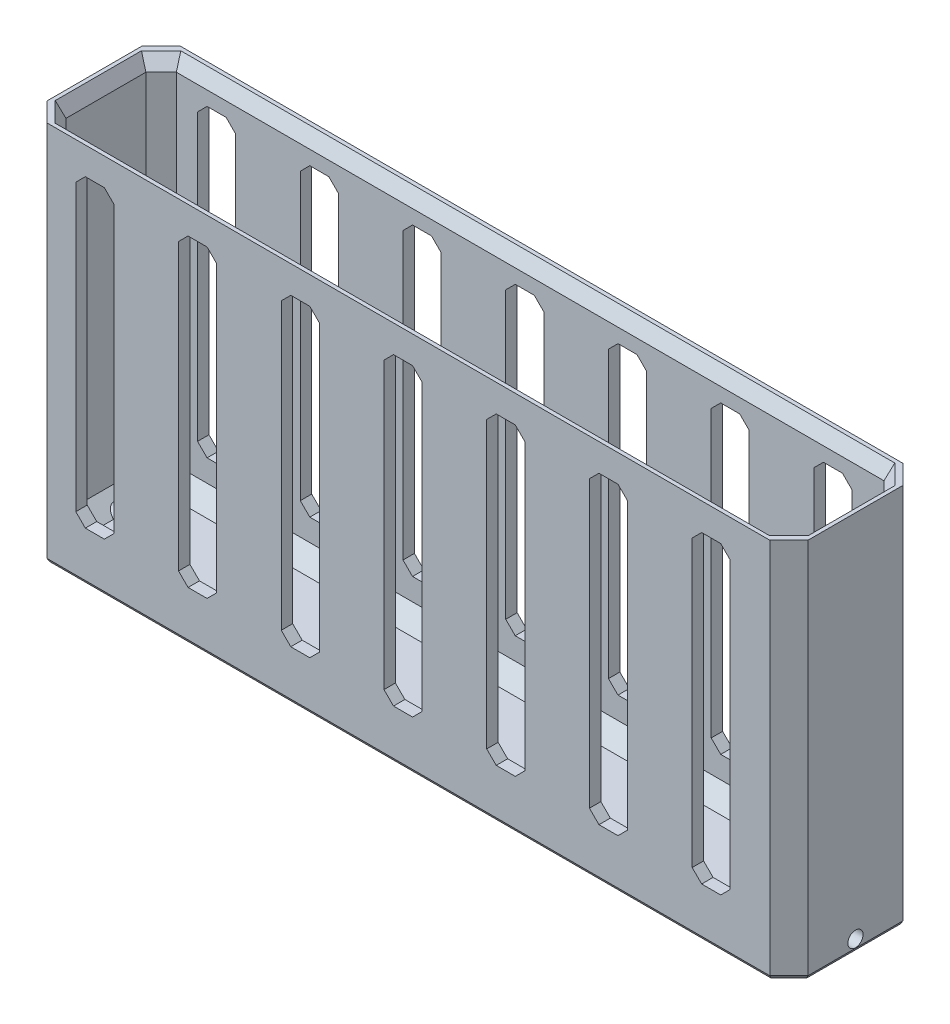
from build123d import *

# Parameters (mm, degrees)
SKETCH1_W           = 200
SKETCH1_H           = 35
SKETCH1_W_2         = 194
SKETCH1_H_2         = 29
BOSS_EXTRUDE1_DEPTH = 100
SKETCH1_3_W         = 194
SKETCH1_3_H         = 29
BOSS_EXTRUDE2_DEPTH = 3
CHAMFER1_SIZE       = 4
CHAMFER2_SIZE       = 5
CHAMFER3_SIZE       = 2
CHAMFER3_SIZE2      = 3.464101615
SKETCH2_R           = 2
CUT_EXTRUDE1_DEPTH  = 10
CHAMFER4_SIZE       = 0.5
CHAMFER4_SIZE2      = 0.866025404
CUT_EXTRUDE2_DEPTH  = 35
LPATTERN2_COUNT     = 7
LPATTERN2_PITCH     = 27


with BuildPart() as part:
    # Sketch1 → Boss-Extrude1 (new body)
    with BuildSketch(Plane(origin=(0, 0, 0), x_dir=(1, 0, 0), z_dir=(0, 1, 0))):
        Rectangle(SKETCH1_W, SKETCH1_H)
        Rectangle(SKETCH1_W_2, SKETCH1_H_2, mode=Mode.SUBTRACT)
    extrude(amount=BOSS_EXTRUDE1_DEPTH)

    # Sketch1_3 → Boss-Extrude2 (add)
    with BuildSketch(Plane(origin=(0, 0, 0), x_dir=(1, 0, 0), z_dir=(0, 1, 0))):
        Rectangle(SKETCH1_3_W, SKETCH1_3_H)
    extrude(amount=BOSS_EXTRUDE2_DEPTH)

    # Chamfer1
    chamfer1_edges = [part.edges().sort_by_distance(p)[0] for p in [
        (97, 51.5, 14.5),
        (97, 51.5, -14.5),
        (-97, 51.5, -14.5),
        (-97, 51.5, 14.5),
        (-97, 3, 0),
        (0, 3, 14.5),
        (97, 3, 0),
        (0, 3, -14.5),
    ]]
    chamfer(chamfer1_edges, length=CHAMFER1_SIZE)

    # Chamfer2
    chamfer2_edges = [part.edges().sort_by_distance(p)[0] for p in [
        (-100, 50, -17.5),
        (100, 50, -17.5),
        (100, 50, 17.5),
        (-100, 50, 17.5),
    ]]
    chamfer(chamfer2_edges, length=CHAMFER2_SIZE)

    # Chamfer3
    chamfer3_edges = [part.edges().sort_by_distance(p)[0] for p in [
        (0, 100, -14.5),
        (97, 100, 0),
        (0, 100, 14.5),
        (-97, 100, 0),
        (95, 100, -12.5),
        (95, 100, 12.5),
        (-95, 100, 12.5),
        (-95, 100, -12.5),
    ]]
    chamfer3_side = [part.faces().sort_by_distance(p)[0] for p in [
        (-97.96960595, 100, 0),
    ]]
    chamfer(chamfer3_edges, length=CHAMFER3_SIZE, length2=CHAMFER3_SIZE2, reference=chamfer3_side[0])

    # Sketch2 → Cut-Extrude1 (cut)
    with BuildSketch(Plane(origin=(100, 0, 0), x_dir=(0, 0, -1), z_dir=(1, 0, 0))):
        with Locations((0, 3)):
            Circle(SKETCH2_R)
    cut_extrude1 = extrude(amount=-CUT_EXTRUDE1_DEPTH, mode=Mode.SUBTRACT)

    # Mirror1: Cut-Extrude1 across plane
    add(cut_extrude1.mirror(Plane(origin=(0, 0, 0), x_dir=(0, 0, 1), z_dir=(1, 0, 0))), mode=Mode.SUBTRACT)

    # Chamfer4
    chamfer4_edges = [part.edges().sort_by_distance(p)[0] for p in [
        (0, 0, -17.5),
        (-100, 0, 0),
        (100, 0, 0),
        (0, 0, 17.5),
        (-97.5, 0, -15),
        (-97.5, 0, 15),
        (97.5, 0, 15),
        (97.5, 0, -15),
    ]]
    chamfer4_side = [part.faces().sort_by_distance(p)[0] for p in [
        (0, 0, 0),
    ]]
    chamfer(chamfer4_edges, length=CHAMFER4_SIZE, length2=CHAMFER4_SIZE2, reference=chamfer4_side[0])

    # Sketch3 → Cut-Extrude2 (cut)
    with BuildSketch(Plane.XY.offset(17.5)):
        Polygon((-87.421150056, 90.293329307), (-84.921150056, 92.793329307), (-79.921150056, 92.793329307), (-77.421150056, 90.293329307), (-77.421150056, 15.293329307), (-79.921150056, 12.793329307), (-84.921150056, 12.793329307), (-87.421150056, 15.293329307), align=None)
    cut_extrude2 = extrude(amount=-CUT_EXTRUDE2_DEPTH, mode=Mode.SUBTRACT)

    # LPattern2: Cut-Extrude2 ×7
    with Locations(*[(i * LPATTERN2_PITCH, 0, 0) for i in range(1, LPATTERN2_COUNT)]):
        add(cut_extrude2, mode=Mode.SUBTRACT)


solid = part.part
